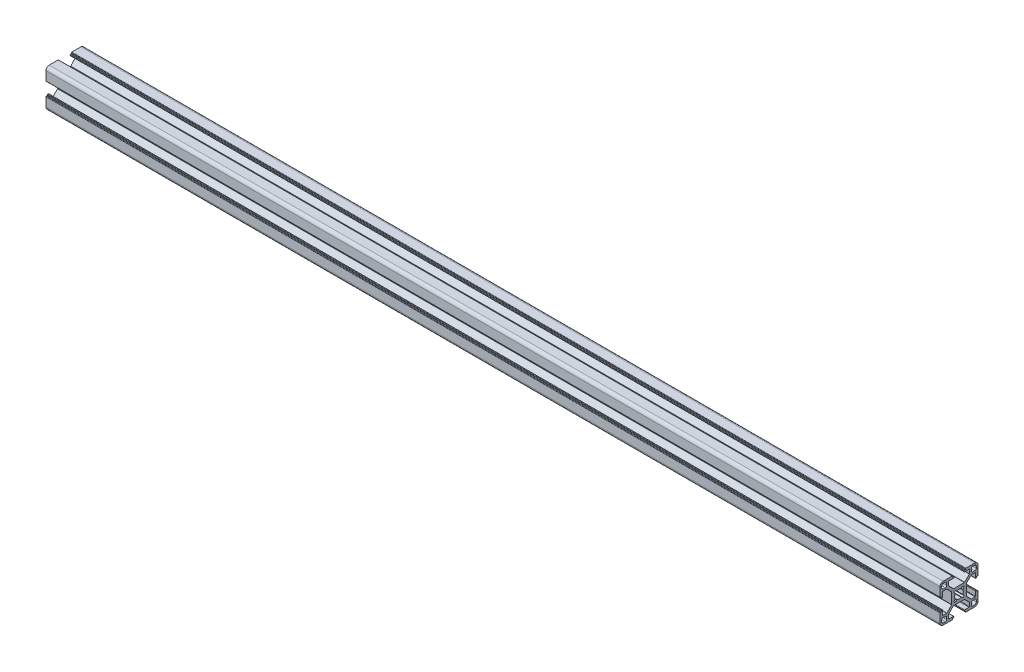
from build123d import *

# Parameters (mm, degrees)
BOSS_EXTRUDE1_DEPTH = 706


with BuildPart() as part:
    # Sketch1 → Boss-Extrude1 (new body)
    with BuildSketch(Plane(origin=(0, 0, 0), x_dir=(0, 0, -1), z_dir=(1, 0, 0))):
        with BuildLine():
            Line((-8.25, 9.788477631), (-8.25, 12.7))
            ThreePointArc((-8.25, 12.7), (-8.162132034, 12.912132034), (-7.95, 13))
            Line((-7.95, 13), (-4.4, 13))
            ThreePointArc((-4.4, 13), (-4.187867966, 13.087867966), (-4.1, 13.3))
            Line((-4.1, 13.3), (-4.1, 13.7))
            ThreePointArc((-4.1, 13.7), (-4.187867966, 13.912132034), (-4.4, 14))
            Line((-4.4, 14), (-4.8, 14))
            ThreePointArc((-4.8, 14), (-5.012132034, 14.087867966), (-5.1, 14.3))
            Line((-5.1, 14.3), (-5.1, 14.7))
            ThreePointArc((-5.1, 14.7), (-5.187867966, 14.912132034), (-5.4, 15))
            Line((-5.4, 15), (-12.5, 15))
            ThreePointArc((-12.5, 15), (-14.267766953, 14.267766953), (-15, 12.5))
            Line((-15, 12.5), (-15, 5.4))
            ThreePointArc((-15, 5.4), (-14.912132034, 5.187867966), (-14.7, 5.1))
            Line((-14.7, 5.1), (-14.3, 5.1))
            ThreePointArc((-14.3, 5.1), (-14.087867966, 5.012132034), (-14, 4.8))
            Line((-14, 4.8), (-14, 4.4))
            ThreePointArc((-14, 4.4), (-13.912132034, 4.187867966), (-13.7, 4.1))
            Line((-13.7, 4.1), (-13.3, 4.1))
            ThreePointArc((-13.3, 4.1), (-13.087867966, 4.187867966), (-13, 4.4))
            Line((-13, 4.4), (-13, 7.95))
            ThreePointArc((-13, 7.95), (-12.912132034, 8.162132034), (-12.7, 8.25))
            Line((-12.7, 8.25), (-9.788477631, 8.25))
            ThreePointArc((-9.788477631, 8.25), (-9.673672601, 8.22716386), (-9.576345597, 8.162132034))
            Line((-9.576345597, 8.162132034), (-5.887867966, 4.473654403))
            ThreePointArc((-5.887867966, 4.473654403), (-5.82283614, 4.376327399), (-5.8, 4.261522369))
            Line((-5.8, 4.261522369), (-5.8, -4.261522369))
            ThreePointArc((-5.8, -4.261522369), (-5.82283614, -4.376327399), (-5.887867966, -4.473654403))
            Line((-5.887867966, -4.473654403), (-9.576345597, -8.162132034))
            ThreePointArc((-9.576345597, -8.162132034), (-9.673672601, -8.22716386), (-9.788477631, -8.25))
            Line((-9.788477631, -8.25), (-12.7, -8.25))
            ThreePointArc((-12.7, -8.25), (-12.912132034, -8.162132034), (-13, -7.95))
            Line((-13, -7.95), (-13, -4.4))
            ThreePointArc((-13, -4.4), (-13.087867966, -4.187867966), (-13.3, -4.1))
            Line((-13.3, -4.1), (-13.7, -4.1))
            ThreePointArc((-13.7, -4.1), (-13.912132034, -4.187867966), (-14, -4.4))
            Line((-14, -4.4), (-14, -4.8))
            ThreePointArc((-14, -4.8), (-14.087867966, -5.012132034), (-14.3, -5.1))
            Line((-14.3, -5.1), (-14.7, -5.1))
            ThreePointArc((-14.7, -5.1), (-14.912132034, -5.187867966), (-15, -5.4))
            Line((-15, -5.4), (-15, -12.5))
            ThreePointArc((-15, -12.5), (-14.267766953, -14.267766953), (-12.5, -15))
            Line((-12.5, -15), (-5.4, -15))
            ThreePointArc((-5.4, -15), (-5.187867966, -14.912132034), (-5.1, -14.7))
            Line((-5.1, -14.7), (-5.1, -14.3))
            ThreePointArc((-5.1, -14.3), (-5.012132034, -14.087867966), (-4.8, -14))
            Line((-4.8, -14), (-4.4, -14))
            ThreePointArc((-4.4, -14), (-4.187867966, -13.912132034), (-4.1, -13.7))
            Line((-4.1, -13.7), (-4.1, -13.3))
            ThreePointArc((-4.1, -13.3), (-4.187867966, -13.087867966), (-4.4, -13))
            Line((-4.4, -13), (-7.95, -13))
            ThreePointArc((-7.95, -13), (-8.162132034, -12.912132034), (-8.25, -12.7))
            Line((-8.25, -12.7), (-8.25, -9.788477631))
            ThreePointArc((-8.25, -9.788477631), (-8.22716386, -9.673672601), (-8.162132034, -9.576345597))
            Line((-8.162132034, -9.576345597), (-4.473654403, -5.887867966))
            ThreePointArc((-4.473654403, -5.887867966), (-4.376327399, -5.82283614), (-4.261522369, -5.8))
            Line((-4.261522369, -5.8), (4.261522369, -5.8))
            ThreePointArc((4.261522369, -5.8), (4.376327399, -5.82283614), (4.473654403, -5.887867966))
            Line((4.473654403, -5.887867966), (8.162132034, -9.576345597))
            ThreePointArc((8.162132034, -9.576345597), (8.22716386, -9.673672601), (8.25, -9.788477631))
            Line((8.25, -9.788477631), (8.25, -12.7))
            ThreePointArc((8.25, -12.7), (8.162132034, -12.912132034), (7.95, -13))
            Line((7.95, -13), (4.4, -13))
            ThreePointArc((4.4, -13), (4.187867966, -13.087867966), (4.1, -13.3))
            Line((4.1, -13.3), (4.1, -13.7))
            ThreePointArc((4.1, -13.7), (4.187867966, -13.912132034), (4.4, -14))
            Line((4.4, -14), (4.8, -14))
            ThreePointArc((4.8, -14), (5.012132034, -14.087867966), (5.1, -14.3))
            Line((5.1, -14.3), (5.1, -14.7))
            ThreePointArc((5.1, -14.7), (5.187867966, -14.912132034), (5.4, -15))
            Line((5.4, -15), (12.5, -15))
            ThreePointArc((12.5, -15), (14.267766953, -14.267766953), (15, -12.5))
            Line((15, -12.5), (15, -5.4))
            ThreePointArc((15, -5.4), (14.912132034, -5.187867966), (14.7, -5.1))
            Line((14.7, -5.1), (14.3, -5.1))
            ThreePointArc((14.3, -5.1), (14.087867966, -5.012132034), (14, -4.8))
            Line((14, -4.8), (14, -4.4))
            ThreePointArc((14, -4.4), (13.912132034, -4.187867966), (13.7, -4.1))
            Line((13.7, -4.1), (13.3, -4.1))
            ThreePointArc((13.3, -4.1), (13.087867966, -4.187867966), (13, -4.4))
            Line((13, -4.4), (13, -7.95))
            ThreePointArc((13, -7.95), (12.912132034, -8.162132034), (12.7, -8.25))
            Line((12.7, -8.25), (9.788477631, -8.25))
            ThreePointArc((9.788477631, -8.25), (9.673672601, -8.22716386), (9.576345597, -8.162132034))
            Line((9.576345597, -8.162132034), (5.887867966, -4.473654403))
            ThreePointArc((5.887867966, -4.473654403), (5.82283614, -4.376327399), (5.8, -4.261522369))
            Line((5.8, -4.261522369), (5.8, 4.261522369))
            ThreePointArc((5.8, 4.261522369), (5.82283614, 4.376327399), (5.887867966, 4.473654403))
            Line((5.887867966, 4.473654403), (9.576345597, 8.162132034))
            ThreePointArc((9.576345597, 8.162132034), (9.673672601, 8.22716386), (9.788477631, 8.25))
            Line((9.788477631, 8.25), (12.7, 8.25))
            ThreePointArc((12.7, 8.25), (12.912132034, 8.162132034), (13, 7.95))
            Line((13, 7.95), (13, 4.4))
            ThreePointArc((13, 4.4), (13.087867966, 4.187867966), (13.3, 4.1))
            Line((13.3, 4.1), (13.7, 4.1))
            ThreePointArc((13.7, 4.1), (13.912132034, 4.187867966), (14, 4.4))
            Line((14, 4.4), (14, 4.8))
            ThreePointArc((14, 4.8), (14.087867966, 5.012132034), (14.3, 5.1))
            Line((14.3, 5.1), (14.7, 5.1))
            ThreePointArc((14.7, 5.1), (14.912132034, 5.187867966), (15, 5.4))
            Line((15, 5.4), (15, 12.5))
            ThreePointArc((15, 12.5), (14.267766953, 14.267766953), (12.5, 15))
            Line((12.5, 15), (5.4, 15))
            ThreePointArc((5.4, 15), (5.187867966, 14.912132034), (5.1, 14.7))
            Line((5.1, 14.7), (5.1, 14.3))
            ThreePointArc((5.1, 14.3), (5.012132034, 14.087867966), (4.8, 14))
            Line((4.8, 14), (4.4, 14))
            ThreePointArc((4.4, 14), (4.187867966, 13.912132034), (4.1, 13.7))
            Line((4.1, 13.7), (4.1, 13.3))
            ThreePointArc((4.1, 13.3), (4.187867966, 13.087867966), (4.4, 13))
            Line((4.4, 13), (7.95, 13))
            ThreePointArc((7.95, 13), (8.162132034, 12.912132034), (8.25, 12.7))
            Line((8.25, 12.7), (8.25, 9.788477631))
            ThreePointArc((8.25, 9.788477631), (8.22716386, 9.673672601), (8.162132034, 9.576345597))
            Line((8.162132034, 9.576345597), (4.473654403, 5.887867966))
            ThreePointArc((4.473654403, 5.887867966), (4.376327399, 5.82283614), (4.261522369, 5.8))
            Line((4.261522369, 5.8), (-4.261522369, 5.8))
            ThreePointArc((-4.261522369, 5.8), (-4.376327399, 5.82283614), (-4.473654403, 5.887867966))
            Line((-4.473654403, 5.887867966), (-8.162132034, 9.576345597))
            ThreePointArc((-8.162132034, 9.576345597), (-8.22716386, 9.673672601), (-8.25, 9.788477631))
        make_face()
        with BuildLine():
            Line((3.05514787, -1.904659815), (3.741964502, -2.698343541))
            ThreePointArc((3.741964502, -2.698343541), (3.70396732, -3.720635173), (2.68151539, -3.75404201))
            Line((2.68151539, -3.75404201), (1.890923385, -3.06366876))
            ThreePointArc((1.890923385, -3.06366876), (1.729867527, -2.991839768), (1.556279141, -3.022911715))
            ThreePointArc((1.556279141, -3.022911715), (0, -3.4), (-1.55627914, -3.022911715))
            ThreePointArc((-1.55627914, -3.022911715), (-1.729867526, -2.991839768), (-1.890923385, -3.06366876))
            Line((-1.890923385, -3.06366876), (-2.68151539, -3.75404201))
            ThreePointArc((-2.68151539, -3.75404201), (-3.70396732, -3.720635173), (-3.741964502, -2.698343541))
            Line((-3.741964502, -2.698343541), (-3.05514787, -1.904659815))
            ThreePointArc((-3.05514787, -1.904659815), (-2.984042722, -1.743283077), (-3.015893746, -1.56983595))
            ThreePointArc((-3.015893746, -1.56983595), (-3.4, 0), (-3.015893746, 1.56983595))
            ThreePointArc((-3.015893746, 1.56983595), (-2.984042722, 1.743283077), (-3.05514787, 1.904659815))
            Line((-3.05514787, 1.904659815), (-3.741964502, 2.698343541))
            ThreePointArc((-3.741964502, 2.698343541), (-3.70396732, 3.720635173), (-2.68151539, 3.75404201))
            Line((-2.68151539, 3.75404201), (-1.890923385, 3.06366876))
            ThreePointArc((-1.890923385, 3.06366876), (-1.729867526, 2.991839768), (-1.55627914, 3.022911715))
            ThreePointArc((-1.55627914, 3.022911715), (0, 3.4), (1.556279141, 3.022911715))
            ThreePointArc((1.556279141, 3.022911715), (1.729867527, 2.991839768), (1.890923385, 3.06366876))
            Line((1.890923385, 3.06366876), (2.68151539, 3.75404201))
            ThreePointArc((2.68151539, 3.75404201), (3.70396732, 3.720635173), (3.741964502, 2.698343541))
            Line((3.741964502, 2.698343541), (3.05514787, 1.904659815))
            ThreePointArc((3.05514787, 1.904659815), (2.984042722, 1.743283077), (3.015893747, 1.56983595))
            ThreePointArc((3.015893747, 1.56983595), (3.4, 0), (3.015893747, -1.56983595))
            ThreePointArc((3.015893747, -1.56983595), (2.984042722, -1.743283077), (3.05514787, -1.904659815))
        make_face(mode=Mode.SUBTRACT)
        with BuildLine():
            Line((10.75, -9.75), (12.65, -9.75))
            ThreePointArc((12.65, -9.75), (13.357106781, -10.042893219), (13.65, -10.75))
            Line((13.65, -10.75), (13.65, -12.15))
            ThreePointArc((13.65, -12.15), (13.210660172, -13.210660172), (12.15, -13.65))
            Line((12.15, -13.65), (10.75, -13.65))
            ThreePointArc((10.75, -13.65), (10.042893219, -13.357106781), (9.75, -12.65))
            Line((9.75, -12.65), (9.75, -10.75))
            ThreePointArc((9.75, -10.75), (10.042893219, -10.042893219), (10.75, -9.75))
        make_face(mode=Mode.SUBTRACT)
        with BuildLine():
            Line((-10.75, 9.75), (-12.65, 9.75))
            ThreePointArc((-12.65, 9.75), (-13.357106781, 10.042893219), (-13.65, 10.75))
            Line((-13.65, 10.75), (-13.65, 12.15))
            ThreePointArc((-13.65, 12.15), (-13.210660172, 13.210660172), (-12.15, 13.65))
            Line((-12.15, 13.65), (-10.75, 13.65))
            ThreePointArc((-10.75, 13.65), (-10.042893219, 13.357106781), (-9.75, 12.65))
            Line((-9.75, 12.65), (-9.75, 10.75))
            ThreePointArc((-9.75, 10.75), (-10.042893219, 10.042893219), (-10.75, 9.75))
        make_face(mode=Mode.SUBTRACT)
        with BuildLine():
            Line((9.75, 10.75), (9.75, 12.65))
            ThreePointArc((9.75, 12.65), (10.042893219, 13.357106781), (10.75, 13.65))
            Line((10.75, 13.65), (12.15, 13.65))
            ThreePointArc((12.15, 13.65), (13.210660172, 13.210660172), (13.65, 12.15))
            Line((13.65, 12.15), (13.65, 10.75))
            ThreePointArc((13.65, 10.75), (13.357106781, 10.042893219), (12.65, 9.75))
            Line((12.65, 9.75), (10.75, 9.75))
            ThreePointArc((10.75, 9.75), (10.042893219, 10.042893219), (9.75, 10.75))
        make_face(mode=Mode.SUBTRACT)
        with BuildLine():
            Line((-9.75, -10.75), (-9.75, -12.65))
            ThreePointArc((-9.75, -12.65), (-10.042893219, -13.357106781), (-10.75, -13.65))
            Line((-10.75, -13.65), (-12.15, -13.65))
            ThreePointArc((-12.15, -13.65), (-13.210660172, -13.210660172), (-13.65, -12.15))
            Line((-13.65, -12.15), (-13.65, -10.75))
            ThreePointArc((-13.65, -10.75), (-13.357106781, -10.042893219), (-12.65, -9.75))
            Line((-12.65, -9.75), (-10.75, -9.75))
            ThreePointArc((-10.75, -9.75), (-10.042893219, -10.042893219), (-9.75, -10.75))
        make_face(mode=Mode.SUBTRACT)
    extrude(amount=BOSS_EXTRUDE1_DEPTH)


solid = part.part
